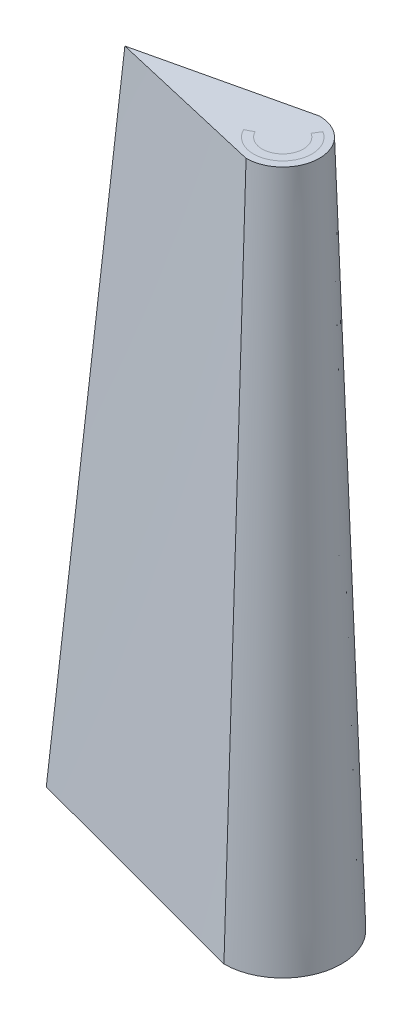
from build123d import *


with BuildPart() as part:
    # Sketch1 → Revolve1 (revolve)
    with BuildSketch(Plane.XY):
        Polygon((-0.762, 2.82502419), (-1.480393248, -22.57497581), (-1.798020213, -22.57497581), (-1.079626965, 2.82502419), align=None)
    revolve(axis=Axis((0, 2.931830397, 0), (0, -1, 0)))


with BuildPart() as body_2:
    # Sketch2 → Loft1 section 0
    with BuildSketch(Plane.XZ.offset(22.57497581)):
        with BuildLine():
            Line((-8.961086966, -0.215231881), (0, 2.174669252))
            ThreePointArc((0, 2.174669252), (2.174669252, 0), (0, -2.174669252))
            Line((0, -2.174669252), (-8.961086966, -0.215231881))
        make_face()
    # Sketch3 → Loft1 section 1
    with BuildSketch(Plane(origin=(0, 2.82502419, 0), x_dir=(1, 0, 0), z_dir=(0, 1, 0))):
        with BuildLine():
            Line((-5.838970763, 0), (0, 1.355751728))
            ThreePointArc((0, 1.355751728), (1.355751728, 0), (0, -1.355751728))
            Line((0, -1.355751728), (-5.838970763, 0))
        make_face()
    loft()


solid = Compound([part.part, body_2.part])
